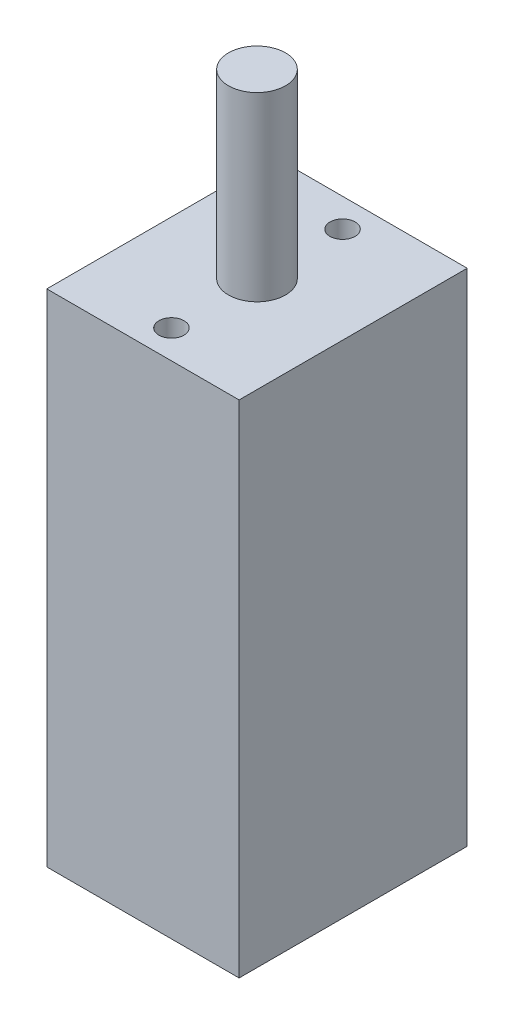
from build123d import *

# Parameters (mm, degrees)
SKETCH1_W          = 10.1092
SKETCH1_H          = 11.9888
EXTRUDE1_DEPTH     = 26.3144
SKETCH2_R          = 1.5
EXTRUDE2_DEPTH     = 9.525
SKETCH3_R          = 0.6604
CUT_EXTRUDE1_DEPTH = 3.175


with BuildPart() as part:
    # Sketch1 → Extrude1 (new body)
    with BuildSketch(Plane(origin=(0, 0, 0), x_dir=(1, 0, 0), z_dir=(0, 1, 0))):
        Rectangle(SKETCH1_W, SKETCH1_H)
    extrude(amount=-EXTRUDE1_DEPTH)

    # Sketch2 → Extrude2 (add)
    with BuildSketch(Plane(origin=(0, 0, 0), x_dir=(-1, 0, 0), z_dir=(0, 1, 0))):
        Circle(SKETCH2_R)
    extrude(amount=EXTRUDE2_DEPTH)

    # Sketch3 → Cut-Extrude1 (cut)
    with BuildSketch(Plane(origin=(0, 0, 0), x_dir=(-1, 0, 0), z_dir=(0, 1, 0))):
        with Locations((0, 4.4958)):
            Circle(SKETCH3_R)
        with Locations((0, -4.4958)):
            Circle(SKETCH3_R)
    extrude(amount=-CUT_EXTRUDE1_DEPTH, mode=Mode.SUBTRACT)


solid = part.part
